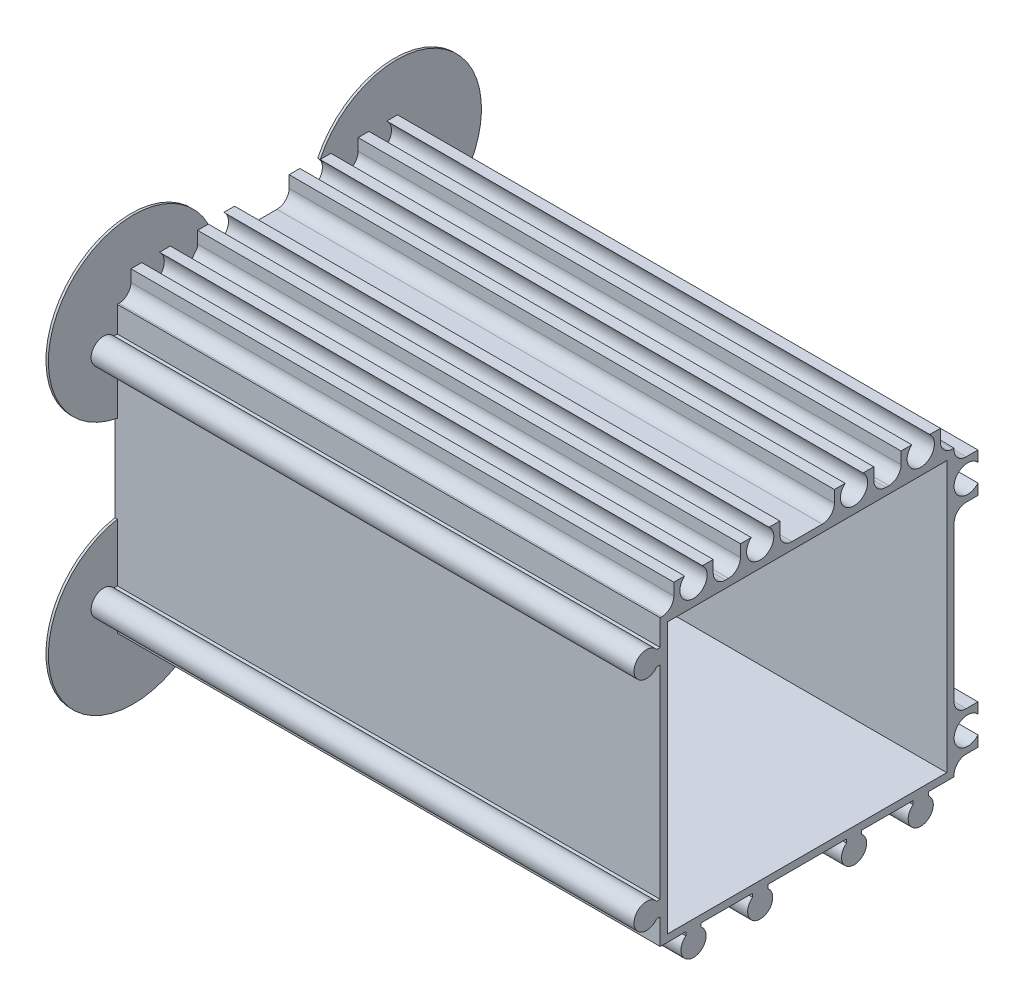
from build123d import *

# Parameters (mm, degrees)
EXTRUDE_1_DEPTH             = 90
SKETCH_2_W                  = 90
SKETCH_2_H                  = 42.75
EXTRUDE_2_DEPTH             = 8.2
SKETCH_3_W                  = 90
SKETCH_3_H                  = 52.45
EXTRUDE_3_DEPTH             = 8.2
SKETCH_4_W                  = 3.95
SKETCH_4_H                  = 2.25
CUT_EXTRUDE_1_DEPTH         = 91
SKETCH_5_W                  = 3.95
SKETCH_5_H                  = 29.5
CUT_EXTRUDE_2_DEPTH         = 91
SKETCH_6_W                  = 3.95
SKETCH_6_H                  = 6.2
CUT_EXTRUDE_3_DEPTH         = 91
SKETCH_7_W                  = 2.25
SKETCH_7_H                  = 3.95
CUT_EXTRUDE_4_DEPTH         = 91
SKETCH_8_W                  = 4.5
SKETCH_8_H                  = 3.95
CUT_EXTRUDE_5_DEPTH         = 91
SKETCH_9_W                  = 9
SKETCH_9_H                  = 3.95
CUT_EXTRUDE_6_DEPTH         = 91
SKETCH_10_W                 = 4.5
SKETCH_10_H                 = 3.95
CUT_EXTRUDE_7_DEPTH         = 91
SKETCH_11_W                 = 2.25
SKETCH_11_H                 = 3.95
CUT_EXTRUDE_8_DEPTH         = 91
SKETCH_12_W                 = 46.1
SKETCH_12_H                 = 44.6
CUT_EXTRUDE_9_DEPTH         = 86.2
HOLE_WIZARD_2_5_2_5_1_D     = 2.5
HOLE_WIZARD_2_5_2_5_1_DEPTH = 90
HOLE_WIZARD_4_5_4_5_1_D     = 4.5
HOLE_WIZARD_4_5_4_5_1_DEPTH = 90
SKETCH_19_R                 = 1.67252853
SKETCH_19_R_2               = 1.459159852
SKETCH_19_R_3               = 1.459908976
SKETCH_19_R_4               = 1.592821911
SKETCH_19_R_5               = 1.532216665
SKETCH_19_R_6               = 1.596138091
EXTRUDE_4_DEPTH             = 90
FILLET_1_R                  = 2
FILLET_2_R                  = 2
FILLET_3_R                  = 2
FILLET_4_R                  = 2
FILLET_5_R                  = 2
FILLET_6_R                  = 2
FILLET_7_R                  = 2
FILLET_8_R                  = 2
FILLET_9_R                  = 2
FILLET_10_R                 = 2
FILLET_11_R                 = 2
FILLET_12_R                 = 2
EXTRUDE_5_DEPTH             = 0.4


with BuildPart() as part:
    # Эскиз1 → Бобышка-Вытянуть1 (new body)
    with BuildSketch(Plane(origin=(90, 0, 0), x_dir=(0, 0, -1), z_dir=(1, 0, 0))):
        with BuildLine():
            Line((6.75, 160.906238208), (6.75, 204.25))
            Line((6.75, 204.25), (-38.093761792, 204.25))
            ThreePointArc((-38.093761792, 204.25), (-41.825, 203), (-38.093761792, 201.75))
            Line((-38.093761792, 201.75), (-37.5, 201.75))
            Line((-37.5, 201.75), (-37.5, 168.25))
            Line((-37.5, 168.25), (-38.093761792, 168.25))
            ThreePointArc((-38.093761792, 168.25), (-41.825, 167), (-38.093761792, 165.75))
            Line((-38.093761792, 165.75), (-37.5, 165.75))
            Line((-37.5, 165.75), (-37.5, 161.5))
            Line((-37.5, 161.5), (-33.25, 161.5))
            Line((-33.25, 161.5), (-33.25, 160.906238208))
            ThreePointArc((-33.25, 160.906238208), (-32, 157.175), (-30.75, 160.906238208))
            Line((-30.75, 160.906238208), (-30.75, 161.5))
            Line((-30.75, 161.5), (-22.25, 161.5))
            Line((-22.25, 161.5), (-22.25, 160.906238208))
            ThreePointArc((-22.25, 160.906238208), (-21, 157.175), (-19.75, 160.906238208))
            Line((-19.75, 160.906238208), (-19.75, 161.5))
            Line((-19.75, 161.5), (-6.75, 161.5))
            Line((-6.75, 161.5), (-6.75, 160.906238208))
            ThreePointArc((-6.75, 160.906238208), (-5.5, 157.175), (-4.25, 160.906238208))
            Line((-4.25, 160.906238208), (-4.25, 161.5))
            Line((-4.25, 161.5), (4.25, 161.5))
            Line((4.25, 161.5), (4.25, 160.906238208))
            ThreePointArc((4.25, 160.906238208), (5.5, 157.175), (6.75, 160.906238208))
        make_face()
    extrude(amount=-EXTRUDE_1_DEPTH)

    # Эскиз2 → Бобышка-Вытянуть2 (add)
    with BuildSketch(Plane(origin=(0, 0, -6.75), x_dir=(-1, 0, 0), z_dir=(0, 0, -1))):
        with Locations((-45, 182.875)):
            Rectangle(SKETCH_2_W, SKETCH_2_H)
    extrude(amount=EXTRUDE_2_DEPTH)

    # Эскиз3 → Бобышка-Вытянуть3 (add)
    with BuildSketch(Plane(origin=(0, 204.25, 0), x_dir=(-1, 0, 0), z_dir=(0, 1, 0))):
        with Locations((-45, 11.275)):
            Rectangle(SKETCH_3_W, SKETCH_3_H)
    extrude(amount=EXTRUDE_3_DEPTH)

    # Эскиз4 → Вырез-Вытянуть1 (cut, through all)
    with BuildSketch(Plane.ZY):
        with Locations((-12.975, 162.625)):
            Rectangle(SKETCH_4_W, SKETCH_4_H)
    extrude(amount=-CUT_EXTRUDE_1_DEPTH, mode=Mode.SUBTRACT)

    # Эскиз5 → Вырез-Вытянуть2 (cut, through all)
    with BuildSketch(Plane.ZY):
        with Locations((-12.975, 185)):
            Rectangle(SKETCH_5_W, SKETCH_5_H)
    extrude(amount=-CUT_EXTRUDE_2_DEPTH, mode=Mode.SUBTRACT)

    # Эскиз6 → Вырез-Вытянуть3 (cut, through all)
    with BuildSketch(Plane.ZY):
        with Locations((-12.975, 209.35)):
            Rectangle(SKETCH_6_W, SKETCH_6_H)
    extrude(amount=-CUT_EXTRUDE_3_DEPTH, mode=Mode.SUBTRACT)

    # Эскиз7 → Вырез-Вытянуть4 (cut, through all)
    with BuildSketch(Plane.ZY):
        with Locations((-9.875, 210.475)):
            Rectangle(SKETCH_7_W, SKETCH_7_H)
    extrude(amount=-CUT_EXTRUDE_4_DEPTH, mode=Mode.SUBTRACT)

    # Эскиз8 → Вырез-Вытянуть5 (cut, through all)
    with BuildSketch(Plane.ZY):
        with Locations((0, 210.475)):
            Rectangle(SKETCH_8_W, SKETCH_8_H)
    extrude(amount=-CUT_EXTRUDE_5_DEPTH, mode=Mode.SUBTRACT)

    # Эскиз9 → Вырез-Вытянуть6 (cut, through all)
    with BuildSketch(Plane.ZY):
        with Locations((13.25, 210.475)):
            Rectangle(SKETCH_9_W, SKETCH_9_H)
    extrude(amount=-CUT_EXTRUDE_6_DEPTH, mode=Mode.SUBTRACT)

    # Эскиз10 → Вырез-Вытянуть7 (cut, through all)
    with BuildSketch(Plane.ZY):
        with Locations((26.5, 210.475)):
            Rectangle(SKETCH_10_W, SKETCH_10_H)
    extrude(amount=-CUT_EXTRUDE_7_DEPTH, mode=Mode.SUBTRACT)

    # Эскиз11 → Вырез-Вытянуть8 (cut, through all)
    with BuildSketch(Plane.ZY):
        with Locations((36.375, 210.475)):
            Rectangle(SKETCH_11_W, SKETCH_11_H)
    extrude(amount=-CUT_EXTRUDE_8_DEPTH, mode=Mode.SUBTRACT)

    # Эскиз12 → Вырез-Вытянуть9 (cut)
    with BuildSketch(Plane(origin=(90, 0, 0), x_dir=(0, 0, -1), z_dir=(1, 0, 0))):
        with Locations((-13.25, 185)):
            Rectangle(SKETCH_12_W, SKETCH_12_H)
    extrude(amount=-CUT_EXTRUDE_9_DEPTH, mode=Mode.SUBTRACT)

    # Диаметр отверстия Ø2.5 (2.5)1
    with Locations(Plane(origin=(90, 0, 0), x_dir=(0, 0, -1), z_dir=(1, 0, 0))):
        with Locations((5.5, 159.25), (-21, 159.25), (-5.5, 159.25), (-32, 159.25), (-39.75, 167), (-39.75, 203)):
            Hole(HOLE_WIZARD_2_5_2_5_1_D / 2, depth=HOLE_WIZARD_2_5_2_5_1_DEPTH)

    # Диаметр отверстия Ø4.5 (4.5)1
    with Locations(Plane.ZY):
        with Locations((-13.25, 167), (-13.25, 203), (-5.5, 210.75), (5.5, 210.75), (21, 210.75), (32, 210.75)):
            Hole(HOLE_WIZARD_4_5_4_5_1_D / 2, depth=HOLE_WIZARD_4_5_4_5_1_DEPTH)

    # Эскиз19 → Бобышка-Вытянуть4 (add)
    with BuildSketch(Plane(origin=(90, 0, 0), x_dir=(0, 0, -1), z_dir=(1, 0, 0))):
        with Locations((-39.75, 203)):
            Circle(SKETCH_19_R)
        with Locations((-39.75, 167)):
            Circle(SKETCH_19_R_2)
        with Locations((-32, 159.25)):
            Circle(SKETCH_19_R_3)
        with Locations((-21, 159.25)):
            Circle(SKETCH_19_R_4)
        with Locations((-5.5, 159.25)):
            Circle(SKETCH_19_R_5)
        with Locations((5.5, 159.25)):
            Circle(SKETCH_19_R_6)
    extrude(amount=-EXTRUDE_4_DEPTH)

    # Скругление1
    fillet_1_edges = [part.edges().sort_by_distance(p)[0] for p in [
        (45, 208.5, -8.75),
    ]]
    fillet(fillet_1_edges, radius=FILLET_1_R)

    # Скругление2
    fillet_2_edges = [part.edges().sort_by_distance(p)[0] for p in [
        (45, 163.75, -11),
    ]]
    fillet(fillet_2_edges, radius=FILLET_2_R)

    # Скругление3
    fillet_3_edges = [part.edges().sort_by_distance(p)[0] for p in [
        (45, 170.25, -11),
    ]]
    fillet(fillet_3_edges, radius=FILLET_3_R)

    # Скругление4
    fillet_4_edges = [part.edges().sort_by_distance(p)[0] for p in [
        (45, 199.75, -11),
    ]]
    fillet(fillet_4_edges, radius=FILLET_4_R)

    # Скругление5
    fillet_5_edges = [part.edges().sort_by_distance(p)[0] for p in [
        (45, 206.25, -11),
    ]]
    fillet(fillet_5_edges, radius=FILLET_5_R)

    # Скругление6
    fillet_6_edges = [part.edges().sort_by_distance(p)[0] for p in [
        (45, 208.5, -2.25),
    ]]
    fillet(fillet_6_edges, radius=FILLET_6_R)

    # Скругление7
    fillet_7_edges = [part.edges().sort_by_distance(p)[0] for p in [
        (45, 208.5, 2.25),
    ]]
    fillet(fillet_7_edges, radius=FILLET_7_R)

    # Скругление8
    fillet_8_edges = [part.edges().sort_by_distance(p)[0] for p in [
        (45, 208.5, 8.75),
    ]]
    fillet(fillet_8_edges, radius=FILLET_8_R)

    # Скругление9
    fillet_9_edges = [part.edges().sort_by_distance(p)[0] for p in [
        (45, 208.5, 17.75),
    ]]
    fillet(fillet_9_edges, radius=FILLET_9_R)

    # Скругление10
    fillet_10_edges = [part.edges().sort_by_distance(p)[0] for p in [
        (45, 208.5, 24.25),
    ]]
    fillet(fillet_10_edges, radius=FILLET_10_R)

    # Скругление11
    fillet_11_edges = [part.edges().sort_by_distance(p)[0] for p in [
        (45, 208.5, 28.75),
    ]]
    fillet(fillet_11_edges, radius=FILLET_11_R)

    # Скругление12
    fillet_12_edges = [part.edges().sort_by_distance(p)[0] for p in [
        (45, 208.5, 35.25),
    ]]
    fillet(fillet_12_edges, radius=FILLET_12_R)

    # Эскиз21 → Бобышка-Вытянуть5 (add)
    with BuildSketch(Plane.ZY):
        with BuildLine():
            Line((-11, 192.615858601), (4.026059703, 212.45))
            ThreePointArc((4.026059703, 212.45), (-19.762874791, 214.863320113), (-11, 192.615858601))
        make_face()
        with BuildLine():
            Line((22.473940297, 212.45), (37.5, 192.207288754))
            ThreePointArc((37.5, 192.207288754), (46.120046397, 214.304143308), (22.473940297, 212.45))
        make_face()
        with BuildLine():
            Line((37.5, 177.792711246), (22.473940297, 157.55))
            ThreePointArc((22.473940297, 157.55), (46.120046397, 155.695856692), (37.5, 177.792711246))
        make_face()
        with BuildLine():
            Line((4.026059703, 157.55), (-11, 177.384141399))
            ThreePointArc((-11, 177.384141399), (-19.762874791, 155.136679887), (4.026059703, 157.55))
        make_face()
    extrude(amount=-EXTRUDE_5_DEPTH)


solid = part.part
